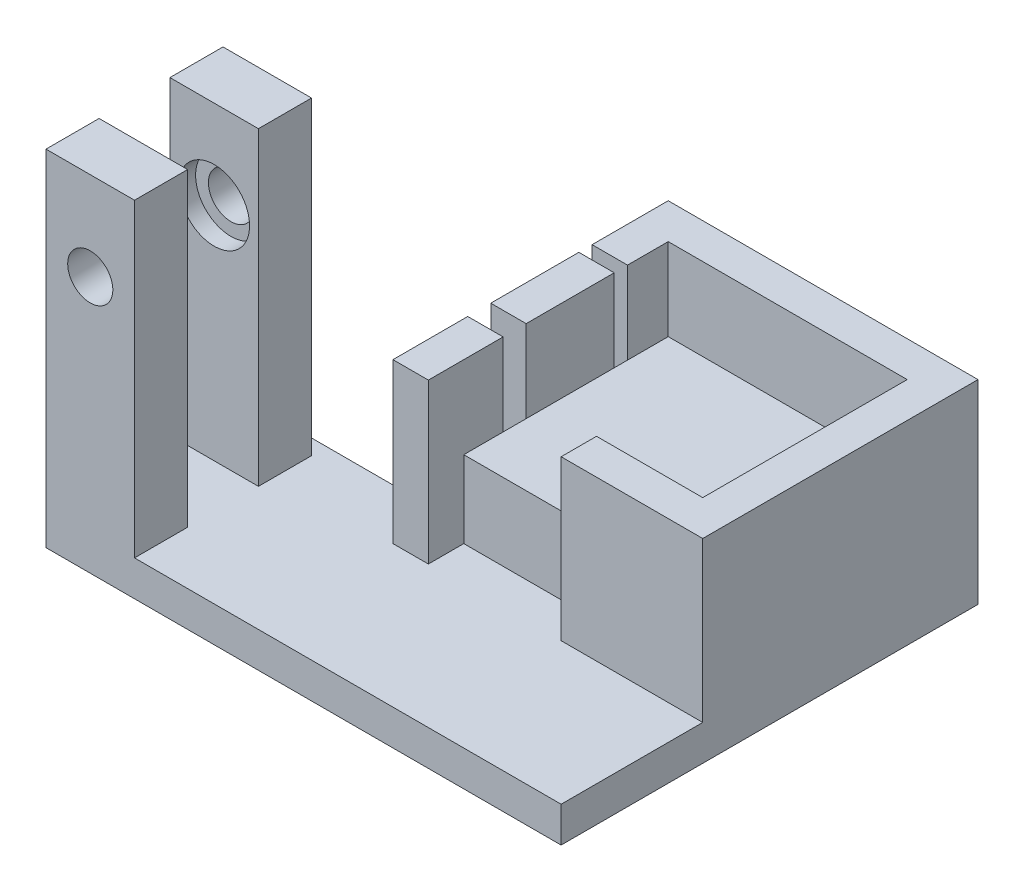
from build123d import *

# Parameters (mm, degrees)
SKETCH1_W           = 60
SKETCH1_H           = 70
BOSS_EXTRUDE1_DEPTH = 4
SKETCH4_W           = 27
SKETCH4_H           = 23.1
BOSS_EXTRUDE3_DEPTH = 8.7
SKETCH3_W           = 10
SKETCH3_H           = 35
SKETCH3_R           = 1.5
BOSS_EXTRUDE2_DEPTH = 6
SKETCH5_W           = 4
SKETCH5_H           = 9.95
SKETCH5_H_2         = 8.45
BOSS_EXTRUDE4_DEPTH = 18
SKETCH6_R           = 2.55
CUT_EXTRUDE1_DEPTH  = 6
SKETCH7_R           = 4
CUT_EXTRUDE2_DEPTH  = 1.9
CUT_EXTRUDE3_REACH  = 6


with BuildPart() as part:
    # Sketch1 → Boss-Extrude1 (new body)
    with BuildSketch(Plane(origin=(0, 0, 0), x_dir=(1, 0, 0), z_dir=(0, 1, 0))):
        with Locations((2.950819672, -17.049180328)):
            Rectangle(SKETCH1_W, SKETCH1_H)
    extrude(amount=BOSS_EXTRUDE1_DEPTH)

    # Sketch4 → Boss-Extrude3 (add)
    with BuildSketch(Plane(origin=(0, 4, 0), x_dir=(1, 0, 0), z_dir=(0, 1, 0))):
        with Locations((15.450819672, -20.499180328)):
            Rectangle(SKETCH4_W, SKETCH4_H)
    extrude(amount=BOSS_EXTRUDE3_DEPTH)

    # Sketch3 → Boss-Extrude2 (add)
    with BuildSketch(Plane.XY.offset(52.049180328)):
        with Locations((-20.249180328, 21.5)):
            Rectangle(SKETCH3_W, SKETCH3_H)
        with Locations((-20.249180328, 29)):
            Circle(SKETCH3_R, mode=Mode.SUBTRACT)
    boss_extrude2 = extrude(amount=-BOSS_EXTRUDE2_DEPTH)

    # Sketch5 → Boss-Extrude4 (add)
    with BuildSketch(Plane(origin=(0, 4, 0), x_dir=(1, 0, 0), z_dir=(0, 1, 0))):
        Polygon((1.950819672, -13.549180328), (1.950819672, -8.949180328), (28.950819672, -8.949180328), (28.950819672, -32.049180328), (16.950819672, -32.049180328), (16.950819672, -36.049180328), (32.950819672, -36.049180328), (32.950819672, -4.949180328), (-2.049180328, -4.949180328), (-2.049180328, -13.549180328), align=None)
        with Locations((-0.049180328, -20.024180328)):
            Rectangle(SKETCH5_W, SKETCH5_H)
        with Locations((-0.049180328, -31.824180328)):
            Rectangle(SKETCH5_W, SKETCH5_H_2)
    extrude(amount=BOSS_EXTRUDE4_DEPTH)

    # Sketch6 → Cut-Extrude1 (cut)
    with BuildSketch(Plane(origin=(0, 0, 46.049180328), x_dir=(-1, 0, 0), z_dir=(0, 0, -1))):
        with Locations((20.249180328, 29)):
            Circle(SKETCH6_R)
    cut_extrude1 = extrude(amount=-CUT_EXTRUDE1_DEPTH, mode=Mode.SUBTRACT)

    # Sketch7 → Cut-Extrude2 (cut)
    with BuildSketch(Plane(origin=(0, 0, 46.049180328), x_dir=(-1, 0, 0), z_dir=(0, 0, -1))):
        with Locations((20.249180328, 29)):
            Circle(SKETCH7_R)
    cut_extrude2 = extrude(amount=-CUT_EXTRUDE2_DEPTH, mode=Mode.SUBTRACT)

    # Mirror1: Boss-Extrude2, Cut-Extrude1, Cut-Extrude2 across plane
    add(boss_extrude2.mirror(Plane(origin=(0, 0, 42.049180328), x_dir=(1, 0, 0), z_dir=(0, 0, -1))))
    add(cut_extrude1.mirror(Plane(origin=(0, 0, 42.049180328), x_dir=(1, 0, 0), z_dir=(0, 0, -1))), mode=Mode.SUBTRACT)
    add(cut_extrude2.mirror(Plane(origin=(0, 0, 42.049180328), x_dir=(1, 0, 0), z_dir=(0, 0, -1))), mode=Mode.SUBTRACT)

    # Sketch9 → Cut-Extrude3 (cut, up to next)
    with BuildSketch(Plane(origin=(0, 4, 0), x_dir=(1, 0, 0), z_dir=(0, 1, 0)), mode=Mode.PRIVATE) as cut_extrude3_sk1:
        Polygon((-2.049180328, -13.549180328), (-2.049180328, -4.949180328), (-27.049180328, -4.949180328), (-27.049180328, -30.311897608), (-25.249180328, -30.311897608), (-2.049180328, -30.311897608), (-2.049180328, -27.599180328), (-2.049180328, -24.999180328), (-2.049180328, -15.049180328), align=None)
    cut_extrude3_tool1 = extrude(cut_extrude3_sk1.sketch, amount=-CUT_EXTRUDE3_REACH, mode=Mode.PRIVATE) & part.part
    add(cut_extrude3_tool1.solids().sort_by_distance((-14.54918, 4, 17.630539))[0], mode=Mode.SUBTRACT)
    # Sketch9 → Cut-Extrude3 (cut, up to next)
    with BuildSketch(Plane(origin=(0, 4, 0), x_dir=(1, 0, 0), z_dir=(0, 1, 0)), mode=Mode.PRIVATE) as cut_extrude3_sk2:
        Polygon((-2.049180328, -4.949180328), (32.950819672, -4.949180328), (32.950819672, 17.950819672), (-27.049180328, 17.950819672), (-27.049180328, -4.949180328), align=None)
    cut_extrude3_tool2 = extrude(cut_extrude3_sk2.sketch, amount=-CUT_EXTRUDE3_REACH, mode=Mode.PRIVATE) & part.part
    add(cut_extrude3_tool2.solids().sort_by_distance((2.95082, 4, -6.50082))[0], mode=Mode.SUBTRACT)
    # Sketch9 → Cut-Extrude3 (cut, up to next)
    with BuildSketch(Plane(origin=(0, 4, 0), x_dir=(1, 0, 0), z_dir=(0, 1, 0)), mode=Mode.PRIVATE) as cut_extrude3_sk3:
        Polygon((-25.249180328, -30.311897608), (-27.049180328, -30.311897608), (-27.049180328, -52.049180328), (-25.249180328, -52.049180328), (-25.249180328, -46.049180328), (-25.249180328, -38.049180328), (-25.249180328, -32.049180328), align=None)
    cut_extrude3_tool3 = extrude(cut_extrude3_sk3.sketch, amount=-CUT_EXTRUDE3_REACH, mode=Mode.PRIVATE) & part.part
    add(cut_extrude3_tool3.solids().sort_by_distance((-26.14918, 4, 41.180539))[0], mode=Mode.SUBTRACT)


solid = part.part
